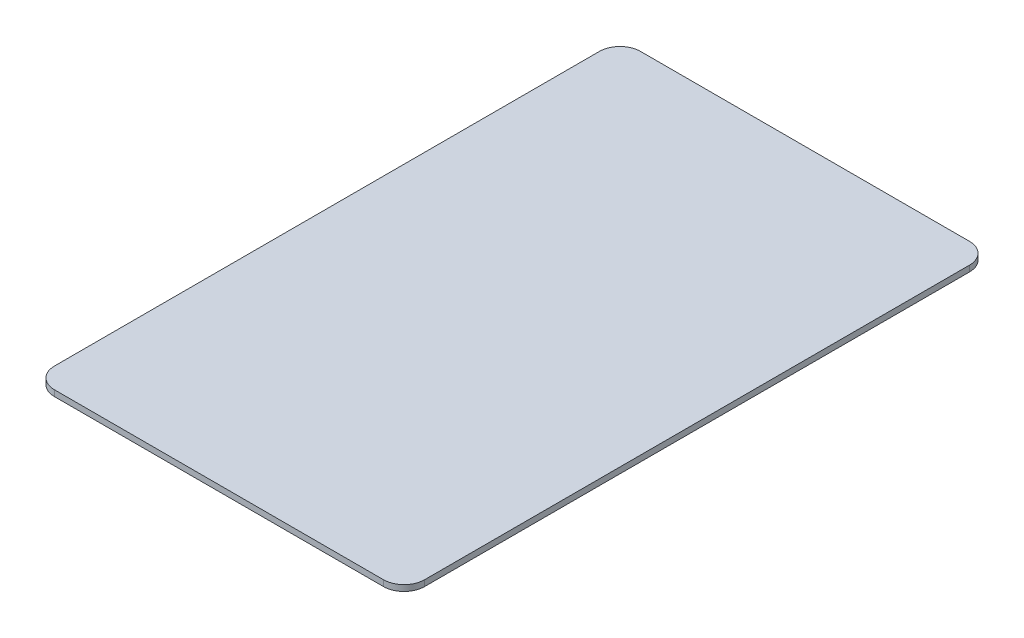
from build123d import *

# Parameters (mm, degrees)
BOSS_EXTRUDE1_DEPTH = 0.87


with BuildPart() as part:
    # Sketch1 → Boss-Extrude1 (new body)
    with BuildSketch(Plane(origin=(0, 0, 0), x_dir=(1, 0, 0), z_dir=(0, 1, 0))):
        with BuildLine():
            Line((-24, -42.75), (24, -42.75))
            ThreePointArc((24, -42.75), (26.121320344, -41.871320344), (27, -39.75))
            Line((27, -39.75), (27, 39.75))
            ThreePointArc((27, 39.75), (26.121320344, 41.871320344), (24, 42.75))
            Line((24, 42.75), (-24, 42.75))
            ThreePointArc((-24, 42.75), (-26.121320344, 41.871320344), (-27, 39.75))
            Line((-27, 39.75), (-27, -39.75))
            ThreePointArc((-27, -39.75), (-26.121320344, -41.871320344), (-24, -42.75))
        make_face()
    extrude(amount=BOSS_EXTRUDE1_DEPTH)


solid = part.part
